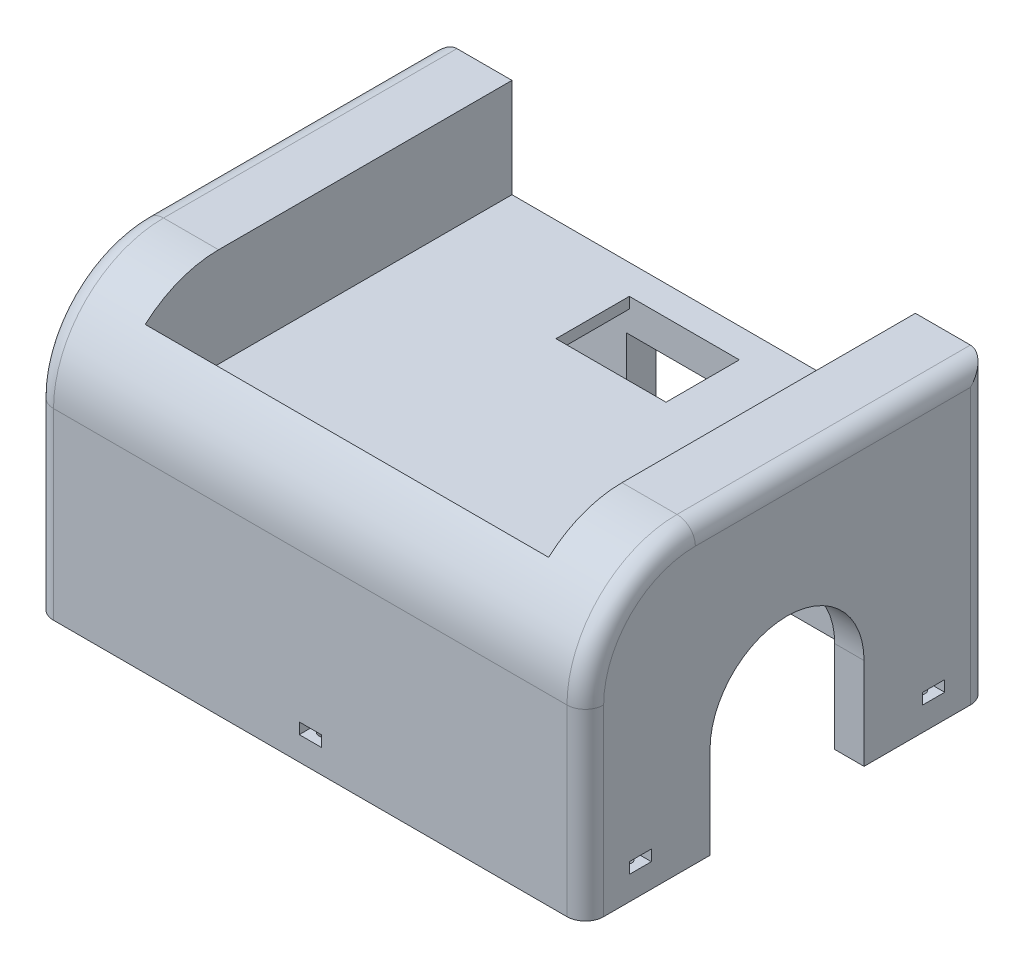
from build123d import *

# Parameters (mm, degrees)
SKETCH_1_W          = 150
SKETCH_1_H          = 110
EXTRUDE_1_DEPTH     = 80
FILLET_3_R          = 30
FILLET_1_R          = 5
CUT_EXTRUDE_1_DEPTH = 151
SKETCH_3_W          = 50
SKETCH_3_H          = 18
CUT_EXTRUDE_2_DEPTH = 50
SKETCH_4_W          = 134
SKETCH_4_H          = 94
CUT_EXTRUDE_3_DEPTH = 50
SKETCH_5_W          = 110
SKETCH_5_H          = 100
CUT_EXTRUDE_4_DEPTH = 27
SKETCH_6_W          = 30
SKETCH_6_H          = 20
CUT_EXTRUDE_5_DEPTH = 23.3
SKETCH_7_W          = 30
SKETCH_7_H          = 20
CUT_EXTRUDE_6_DEPTH = 23.3
SKETCH_8_R          = 1.65
CUT_EXTRUDE_7_DEPTH = 10
SKETCH_11_W         = 6
SKETCH_11_H         = 3
CUT_EXTRUDE_8_DEPTH = 161
SKETCH_12_W         = 6
SKETCH_12_H         = 3
CUT_EXTRUDE_9_DEPTH = 161


with BuildPart() as part:
    # 草图1 → 凸台-拉伸1 (new body)
    with BuildSketch(Plane(origin=(0, 0, 0), x_dir=(1, 0, 0), z_dir=(0, 1, 0))):
        Rectangle(SKETCH_1_W, SKETCH_1_H)
    extrude(amount=EXTRUDE_1_DEPTH)

    # 圆角3
    fillet_3_edges = [part.edges().sort_by_distance(p)[0] for p in [
        (0, 80, 55),
    ]]
    fillet(fillet_3_edges, radius=FILLET_3_R)

    # 圆角1
    fillet_1_edges = [part.edges().sort_by_distance(p)[0] for p in [
        (-75, 80, -15),
        (75, 80, -15),
        (75, 25, 55),
        (75, 71.213203436, 46.213203436),
        (-75, 25, 55),
        (-75, 71.213203436, 46.213203436),
        (-75, 40, -55),
        (75, 40, -55),
    ]]
    fillet(fillet_1_edges, radius=FILLET_1_R)

    # 草图2 → 切除-拉伸1 (cut, through all)
    with BuildSketch(Plane(origin=(75, 0, 0), x_dir=(0, 0, -1), z_dir=(1, 0, 0))):
        with BuildLine():
            Line((-21, 25), (-21, 0))
            Line((-21, 0), (21, 0))
            Line((21, 0), (21, 25))
            ThreePointArc((21, 25), (0, 46), (-21, 25))
        make_face()
    extrude(amount=-CUT_EXTRUDE_1_DEPTH, mode=Mode.SUBTRACT)

    # 草图3 → 切除-拉伸2 (cut)
    with BuildSketch(Plane(origin=(0, 0, -55), x_dir=(-1, 0, 0), z_dir=(0, 0, -1))):
        with Locations((0, 9)):
            Rectangle(SKETCH_3_W, SKETCH_3_H)
    extrude(amount=-CUT_EXTRUDE_2_DEPTH, mode=Mode.SUBTRACT)

    # 草图4 → 切除-拉伸3 (cut)
    with BuildSketch(Plane.XZ):
        Rectangle(SKETCH_4_W, SKETCH_4_H)
    extrude(amount=-CUT_EXTRUDE_3_DEPTH, mode=Mode.SUBTRACT)

    # 草图5 → 切除-拉伸4 (cut)
    with BuildSketch(Plane(origin=(0, 80, 0), x_dir=(1, 0, 0), z_dir=(0, 1, 0))):
        with Locations((0, 5)):
            Rectangle(SKETCH_5_W, SKETCH_5_H)
    extrude(amount=-CUT_EXTRUDE_4_DEPTH, mode=Mode.SUBTRACT)

    # 草图6 → 切除-拉伸5 (cut)
    with BuildSketch(Plane(origin=(0, 0, -55), x_dir=(-1, 0, 0), z_dir=(0, 0, -1))):
        with Locations((0.741149686, 34)):
            Rectangle(SKETCH_6_W, SKETCH_6_H)
    extrude(amount=-CUT_EXTRUDE_5_DEPTH, mode=Mode.SUBTRACT)

    # 草图7 → 切除-拉伸6 (cut)
    with BuildSketch(Plane(origin=(0, 53, 0), x_dir=(1, 0, 0), z_dir=(0, 1, 0))):
        with Locations((0, 37)):
            Rectangle(SKETCH_7_W, SKETCH_7_H)
    extrude(amount=-CUT_EXTRUDE_6_DEPTH, mode=Mode.SUBTRACT)

    # 草图8 → 切除-拉伸7 (cut)
    with BuildSketch(Plane.XZ):
        with Locations((71, 40)):
            Circle(SKETCH_8_R)
        with Locations((71, -40)):
            Circle(SKETCH_8_R)
        with Locations((-71, -40)):
            Circle(SKETCH_8_R)
        with Locations((-71, 40)):
            Circle(SKETCH_8_R)
        with Locations((0, 51)):
            Circle(SKETCH_8_R)
    extrude(amount=-CUT_EXTRUDE_7_DEPTH, mode=Mode.SUBTRACT)

    # 草图11 → 切除-拉伸8 (cut)
    with BuildSketch(Plane.ZY.offset(75)):
        with Locations((-40, 8)):
            Rectangle(SKETCH_11_W, SKETCH_11_H)
        with Locations((40, 8)):
            Rectangle(SKETCH_11_W, SKETCH_11_H)
    extrude(amount=-CUT_EXTRUDE_8_DEPTH, mode=Mode.SUBTRACT)

    # 草图12 → 切除-拉伸9 (cut)
    with BuildSketch(Plane.XY.offset(55)):
        with Locations((0, 8)):
            Rectangle(SKETCH_12_W, SKETCH_12_H)
    extrude(amount=-CUT_EXTRUDE_9_DEPTH, mode=Mode.SUBTRACT)


solid = part.part
